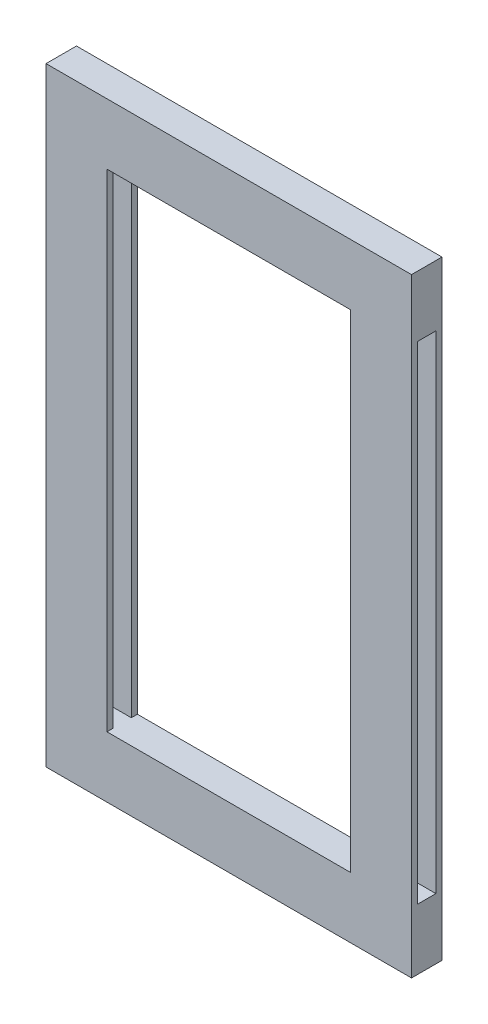
from build123d import *

# Parameters (mm, degrees)
CROQUIS1_W              = 60
CROQUIS1_H              = 100
SALIENTE_EXTRUIR1_DEPTH = 5
CROQUIS3_W              = 3
CROQUIS3_H              = 80
CORTAR_EXTRUIR2_DEPTH   = 60
CROQUIS4_W              = 40
CROQUIS4_H              = 80
CORTAR_EXTRUIR3_DEPTH   = 28


with BuildPart() as part:
    # Croquis1 → Saliente-Extruir1 (new body)
    with BuildSketch(Plane.XY):
        with Locations((-30, 50)):
            Rectangle(CROQUIS1_W, CROQUIS1_H)
    extrude(amount=SALIENTE_EXTRUIR1_DEPTH)

    # Croquis3 → Cortar-Extruir2 (cut)
    with BuildSketch(Plane.ZY.offset(60)):
        with Locations((2.5, 50)):
            Rectangle(CROQUIS3_W, CROQUIS3_H)
    extrude(amount=-CORTAR_EXTRUIR2_DEPTH, mode=Mode.SUBTRACT)

    # Croquis4 → Cortar-Extruir3 (cut)
    with BuildSketch(Plane(origin=(0, 0, 0), x_dir=(-1, 0, 0), z_dir=(0, 0, -1))):
        with Locations((30, 50)):
            Rectangle(CROQUIS4_W, CROQUIS4_H)
    extrude(amount=-CORTAR_EXTRUIR3_DEPTH, mode=Mode.SUBTRACT)


solid = part.part
